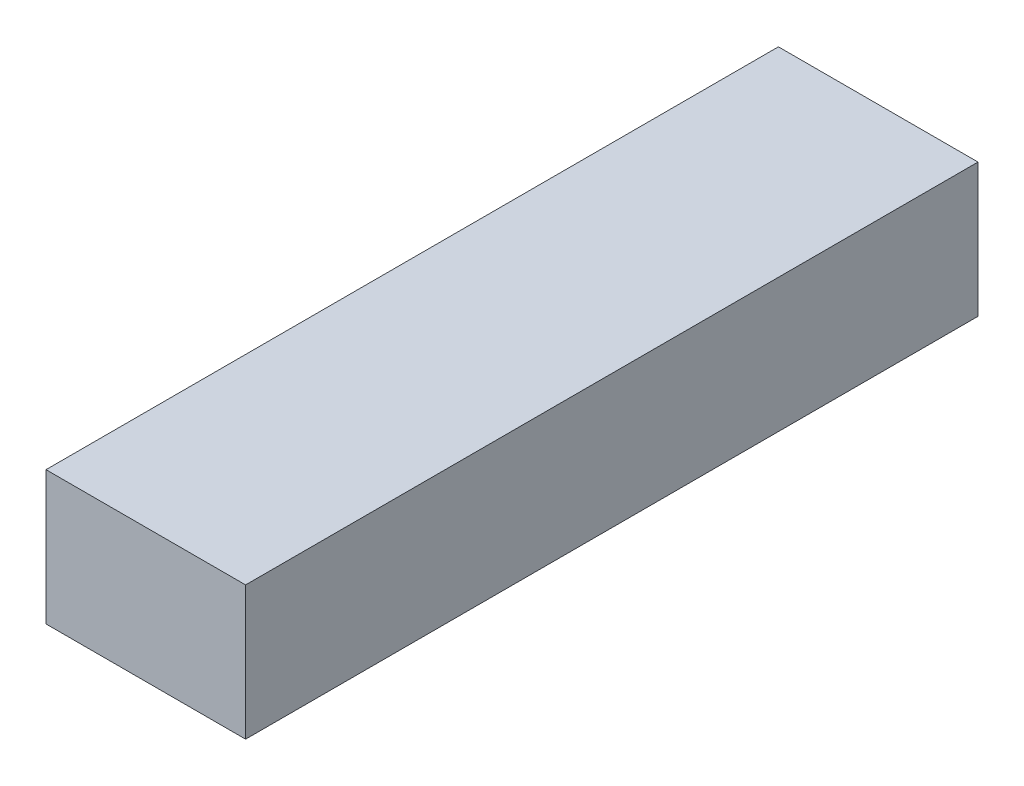
from build123d import *

# Parameters (mm, degrees)
CROQUIS1_W              = 29.972
CROQUIS1_H              = 109.982
SALIENTE_EXTRUIR1_DEPTH = 20.066


with BuildPart() as part:
    # Croquis1 → Saliente-Extruir1 (new body)
    with BuildSketch(Plane(origin=(0, 0, 0), x_dir=(1, 0, 0), z_dir=(0, 1, 0))):
        Rectangle(CROQUIS1_W, CROQUIS1_H)
    extrude(amount=SALIENTE_EXTRUIR1_DEPTH)


solid = part.part
